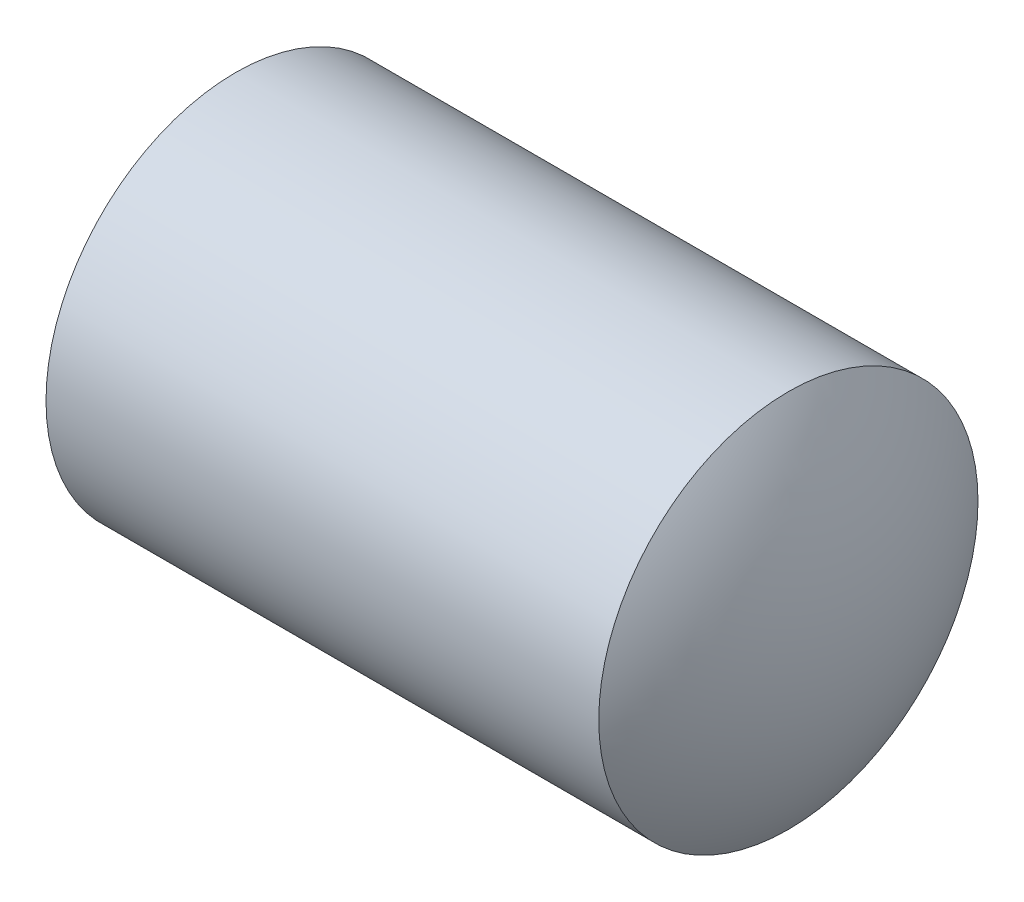
from build123d import *

# Parameters (mm, degrees)
HEX_2_DEPTH = 2.1


with BuildPart() as part:
    # BodySke → BaseBody (revolve)
    with BuildSketch(Plane.XY):
        with BuildLine():
            Line((0, 0), (0, 1.2195))
            Line((0, 1.2195), (0.161946751, 1.5))
            Line((0.161946751, 1.5), (4.534605227, 1.5))
            ThreePointArc((4.534605227, 1.5), (4.880978452, 0.785269427), (5, 0))
            Line((5, 0), (0, 0))
        make_face()
    revolve(axis=Axis((-12.7, 0, 0), (1, 0, 0)))

    # Sketch2 → Hex 2 (cut)
    with BuildSketch(Plane.ZY):
        Polygon((0.433012702, 0.75), (-0.433012702, 0.75), (-0.866025404, 0), (-0.433012702, -0.75), (0.433012702, -0.75), (0.866025404, 0), align=None)
    extrude(amount=-HEX_2_DEPTH, mode=Mode.SUBTRACT)


solid = part.part
